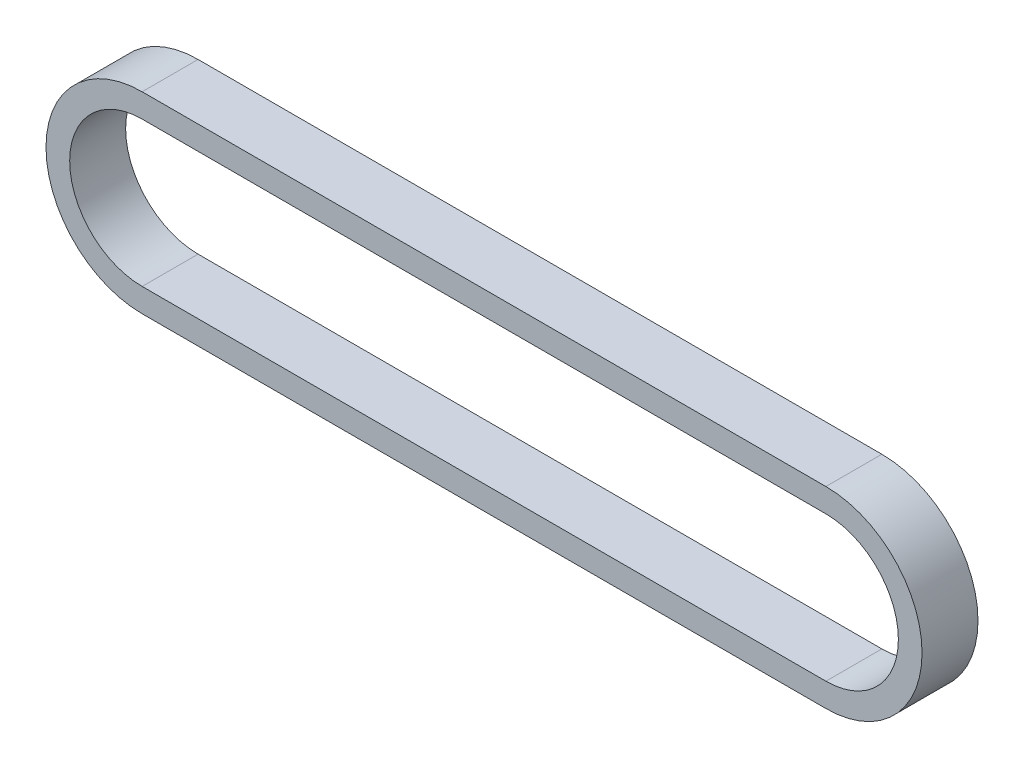
from build123d import *

# Parameters (mm, degrees)
EXTRUDE_THIN1_DEPTH = 4.5


with BuildPart() as part:
    # Sketch1 → Extrude-Thin1 (new body, symmetric)
    with BuildSketch(Plane.XY):
        with BuildLine():
            Line((109.999999964, -15.466956708), (0, -15.466956708))
            ThreePointArc((0, -15.466956708), (-15.466956708, 0), (0, 15.466956708))
            Line((0, 15.466956708), (109.999999964, 15.466956708))
            ThreePointArc((109.999999964, 15.466956708), (125.466956672, 0), (109.999999964, -15.466956708))
        make_face()
        with BuildLine():
            Line((109.999999964, -11.656956708), (0, -11.656956708))
            ThreePointArc((0, -11.656956708), (-11.656956708, 0), (0, 11.656956708))
            Line((0, 11.656956708), (109.999999964, 11.656956708))
            ThreePointArc((109.999999964, 11.656956708), (121.656956672, 0), (109.999999964, -11.656956708))
        make_face(mode=Mode.SUBTRACT)
    extrude(amount=EXTRUDE_THIN1_DEPTH, both=True)


solid = part.part
